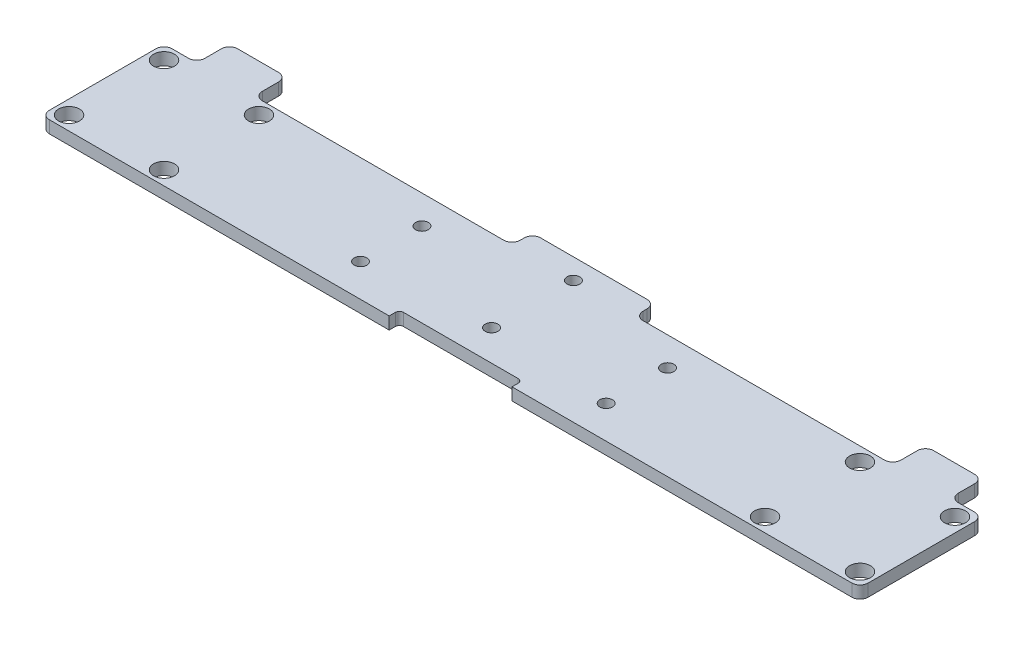
from build123d import *

# Parameters (mm, degrees)
CROQUIS1_R              = 2.55
CROQUIS1_R_2            = 1.55
SALIENTE_EXTRUIR1_DEPTH = 3
REDONDEO2_R             = 2
CORTAR_EXTRUIR1_DEPTH   = 3


with BuildPart() as part:
    # Croquis1 → Saliente-Extruir1 (new body)
    with BuildSketch(Plane(origin=(0, 0, 0), x_dir=(1, 0, 0), z_dir=(0, 1, 0))):
        Polygon((0, 0), (200, 0), (200, 30), (192, 30), (192, 38), (178, 38), (178, 30), (115, 30), (115, 35), (85, 35), (85, 30), (22, 30), (22, 38), (8, 38), (8, 30), (0, 30), align=None)
        with Locations((3.4, 26.6)):
            Circle(CROQUIS1_R, mode=Mode.SUBTRACT)
        with Locations((26.6, 26.6)):
            Circle(CROQUIS1_R, mode=Mode.SUBTRACT)
        with Locations((26.6, 3.4)):
            Circle(CROQUIS1_R, mode=Mode.SUBTRACT)
        with Locations((3.4, 3.4)):
            Circle(CROQUIS1_R, mode=Mode.SUBTRACT)
        with Locations((173.4, 3.4)):
            Circle(CROQUIS1_R, mode=Mode.SUBTRACT)
        with Locations((196.6, 3.4)):
            Circle(CROQUIS1_R, mode=Mode.SUBTRACT)
        with Locations((196.6, 26.6)):
            Circle(CROQUIS1_R, mode=Mode.SUBTRACT)
        with Locations((173.4, 26.6)):
            Circle(CROQUIS1_R, mode=Mode.SUBTRACT)
        with Locations((100, 30)):
            Circle(CROQUIS1_R_2, mode=Mode.SUBTRACT)
        with Locations((100, 10)):
            Circle(CROQUIS1_R_2, mode=Mode.SUBTRACT)
        with Locations((70, 23)):
            Circle(CROQUIS1_R_2, mode=Mode.SUBTRACT)
        with Locations((70, 8)):
            Circle(CROQUIS1_R_2, mode=Mode.SUBTRACT)
        with Locations((130, 8)):
            Circle(CROQUIS1_R_2, mode=Mode.SUBTRACT)
        with Locations((130, 23)):
            Circle(CROQUIS1_R_2, mode=Mode.SUBTRACT)
    extrude(amount=SALIENTE_EXTRUIR1_DEPTH)

    # Redondeo2
    redondeo2_edges = [part.edges().sort_by_distance(p)[0] for p in [
        (0, 1.5, -30),
        (8, 1.5, -30),
        (8, 1.5, -38),
        (22, 1.5, -38),
        (22, 1.5, -30),
        (85, 1.5, -30),
        (85, 1.5, -35),
        (115, 1.5, -35),
        (115, 1.5, -30),
        (178, 1.5, -30),
        (178, 1.5, -38),
        (192, 1.5, -38),
        (192, 1.5, -30),
        (200, 1.5, -30),
        (200, 1.5, 0),
        (0, 1.5, 0),
    ]]
    fillet(redondeo2_edges, radius=REDONDEO2_R)

    # Croquis2 → Cortar-Extruir1 (cut)
    with BuildSketch(Plane(origin=(0, 3, 0), x_dir=(1, 0, 0), z_dir=(0, 1, 0))):
        with BuildLine():
            Line((85, 0), (115, 0))
            Line((115, 0), (115, 1.5))
            ThreePointArc((115, 1.5), (114.707106781, 2.207106781), (114, 2.5))
            Line((114, 2.5), (86, 2.5))
            ThreePointArc((86, 2.5), (85.292893219, 2.207106781), (85, 1.5))
            Line((85, 1.5), (85, 0))
        make_face()
    extrude(amount=-CORTAR_EXTRUIR1_DEPTH, mode=Mode.SUBTRACT)


solid = part.part
